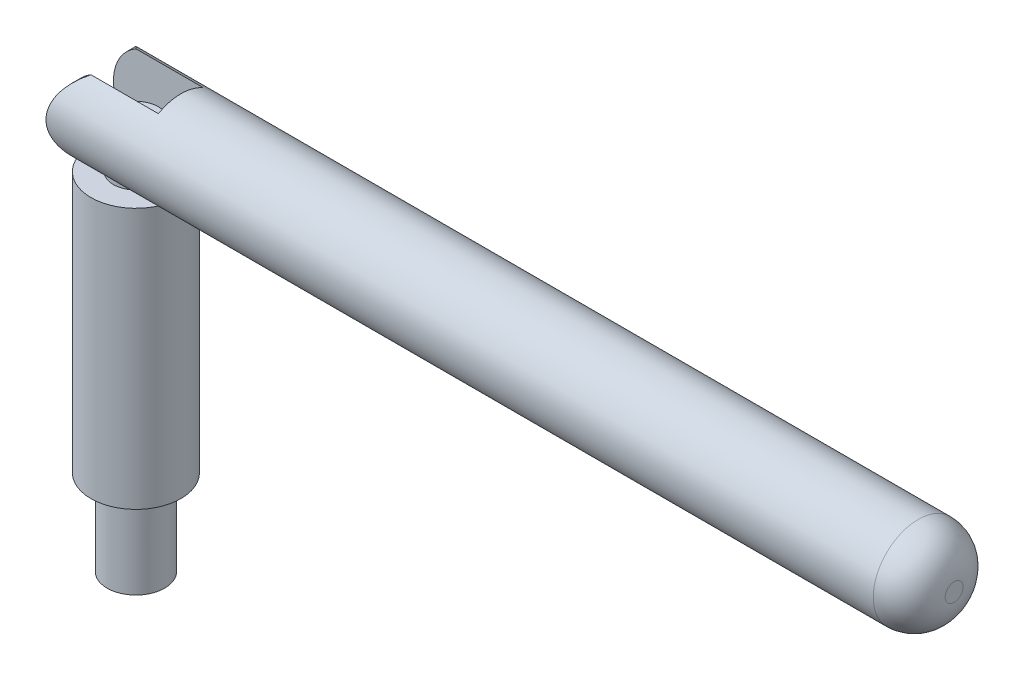
from build123d import *

# Parameters (mm, degrees)
SKETCH1_R                = 5
BOSS_EXTRUDE1_DEPTH      = 29
SKETCH2_R                = 2.5
BOSS_EXTRUDE2_DEPTH      = 5
SKETCH4_R                = 3.2
BOSS_EXTRUDE3_DEPTH      = 9.525
SKETCH5_R                = 5
BOSS_EXTRUDE4_DEPTH      = 86
BOSS_EXTRUDE4_DEPTH_BACK = 10
FILLET1_R                = 4
SKETCH8_W                = 10
SKETCH8_H                = 5
CUT_EXTRUDE2_DEPTH       = 11
CUT_EXTRUDE3_DEPTH       = 6
CUT_EXTRUDE3_DEPTH_BACK  = 6


with BuildPart() as part:
    # Sketch1 → Boss-Extrude1 (new body)
    with BuildSketch(Plane(origin=(0, 0, 0), x_dir=(1, 0, 0), z_dir=(0, 1, 0))):
        Circle(SKETCH1_R)
    extrude(amount=BOSS_EXTRUDE1_DEPTH)

    # Sketch2 → Boss-Extrude2 (add)
    with BuildSketch(Plane(origin=(0, 29, 0), x_dir=(1, 0, 0), z_dir=(0, 1, 0))):
        Circle(SKETCH2_R)
    extrude(amount=BOSS_EXTRUDE2_DEPTH)

    # Sketch4 → Boss-Extrude3 (add)
    with BuildSketch(Plane.XZ):
        Circle(SKETCH4_R)
    extrude(amount=BOSS_EXTRUDE3_DEPTH)


with BuildPart() as body_2:
    # Sketch5 → Boss-Extrude4 (new body, two sides)
    with BuildSketch(Plane(origin=(5, 0, 0), x_dir=(0, 0, -1), z_dir=(1, 0, 0))) as boss_extrude4_sk:
        with Locations((0, 34)):
            Circle(SKETCH5_R)
    extrude(amount=BOSS_EXTRUDE4_DEPTH)
    extrude(boss_extrude4_sk.sketch, amount=-BOSS_EXTRUDE4_DEPTH_BACK)

    # Fillet1
    fillet1_edges = [body_2.edges().sort_by_distance(p)[0] for p in [
        (91, 34, 5),
    ]]
    fillet(fillet1_edges, radius=FILLET1_R)

    # Sketch8 → Cut-Extrude2 (cut, through all)
    with BuildSketch(Plane(origin=(0, 29, 0), x_dir=(1, 0, 0), z_dir=(0, 1, 0))):
        Rectangle(SKETCH8_W, SKETCH8_H)
    extrude(amount=CUT_EXTRUDE2_DEPTH, mode=Mode.SUBTRACT)

    # Sketch9 → Cut-Extrude3 (cut, two sides)
    with BuildSketch(Plane.XY) as cut_extrude3_sk:
        with BuildLine():
            Line((-5, 34), (-5, 29))
            Line((-5, 29), (0, 29))
            ThreePointArc((0, 29), (-3.535533906, 30.464466094), (-5, 34))
        make_face()
        with BuildLine():
            Line((-5, 39), (-5, 34))
            ThreePointArc((-5, 34), (-3.535533906, 37.535533906), (0, 39))
            Line((0, 39), (-5, 39))
        make_face()
    extrude(amount=CUT_EXTRUDE3_DEPTH, mode=Mode.SUBTRACT)
    extrude(cut_extrude3_sk.sketch, amount=-CUT_EXTRUDE3_DEPTH_BACK, mode=Mode.SUBTRACT)


solid = Compound([part.part, body_2.part])
